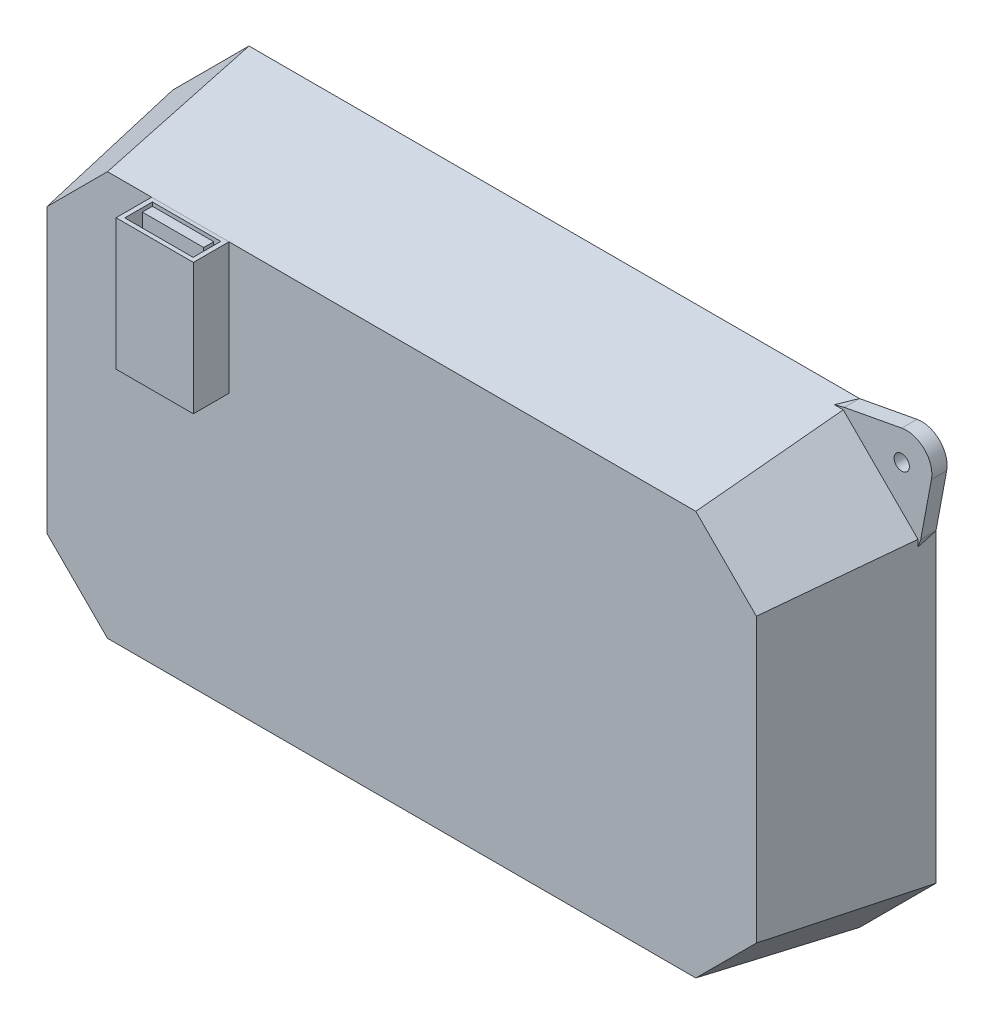
from build123d import *

# Parameters (mm, degrees)
BOSS_EXTRUDE1_DEPTH = 30
BOSS_EXTRUDE1_TAPER = 10
SHELL1_T            = -5
SKETCH6_W           = 15.197518051
SKETCH6_H           = 25.772318446
BOSS_EXTRUDE4_DEPTH = 7
SKETCH7_W           = 13.433844537
SKETCH7_H           = 5.428745395
SKETCH7_W_2         = 12.053655029
SKETCH7_H_2         = 1.978271627
CUT_EXTRUDE2_DEPTH  = 17
SKETCH8_R           = 1.5
BOSS_EXTRUDE5_DEPTH = 3


with BuildPart() as part:
    # Sketch1 → Boss-Extrude1 (new body)
    with BuildSketch(Plane.XY):
        Polygon((-100, 10.531931481), (-100, -49.468068519), (-85, -64.468068519), (35, -64.468068519), (50, -49.468068519), (50, 10.531931481), (35, 25.531931481), (-85, 25.531931481), align=None)
    extrude(amount=BOSS_EXTRUDE1_DEPTH, taper=BOSS_EXTRUDE1_TAPER)

    # Shell1
    shell1_openings = [part.faces().sort_by_distance(p)[0] for p in [
        (-25, -19.468068519, 0),
    ]]
    offset(amount=SHELL1_T, openings=shell1_openings, kind=Kind.INTERSECTION)

    # Sketch6 → Boss-Extrude4 (add)
    with BuildSketch(Plane.XY.offset(30)):
        with Locations((-66.525501272, 7.355962837)):
            Rectangle(SKETCH6_W, SKETCH6_H)
    extrude(amount=BOSS_EXTRUDE4_DEPTH)

    # Sketch7 → Cut-Extrude2 (cut)
    with BuildSketch(Plane(origin=(0, 20.24212206, 0), x_dir=(1, 0, 0), z_dir=(0, 1, 0))):
        with Locations((-66.527599538, -33.454113167)):
            Rectangle(SKETCH7_W, SKETCH7_H)
        with Locations((-66.481593222, -32.464977353)):
            Rectangle(SKETCH7_W_2, SKETCH7_H_2, mode=Mode.SUBTRACT)
    extrude(amount=-CUT_EXTRUDE2_DEPTH, mode=Mode.SUBTRACT)


with BuildPart() as body_2:
    # Sketch8 → Boss-Extrude5 (new body)
    with BuildSketch(Plane(origin=(0, 0, 0), x_dir=(-1, 0, 0), z_dir=(0, 0, -1))):
        with BuildLine():
            ThreePointArc((-52.108034043, 21.80617699), (-50.728742794, 26.260674275), (-46.274245509, 27.639965524))
            Line((-46.274245509, 27.639965524), (-35, 25.531931481))
            Line((-35, 25.531931481), (-50, 10.531931481))
            Line((-50, 10.531931481), (-52.108034043, 21.80617699))
        make_face()
        with Locations((-46.274245509, 21.80617699)):
            Circle(SKETCH8_R, mode=Mode.SUBTRACT)
        Polygon((-49.062232862, 7.849935369), (-31.845274645, 24.682449772), (-35, 25.531931481), (-50, 10.531931481), align=None)
    extrude(amount=-BOSS_EXTRUDE5_DEPTH)


solid = Compound([part.part, body_2.part])
